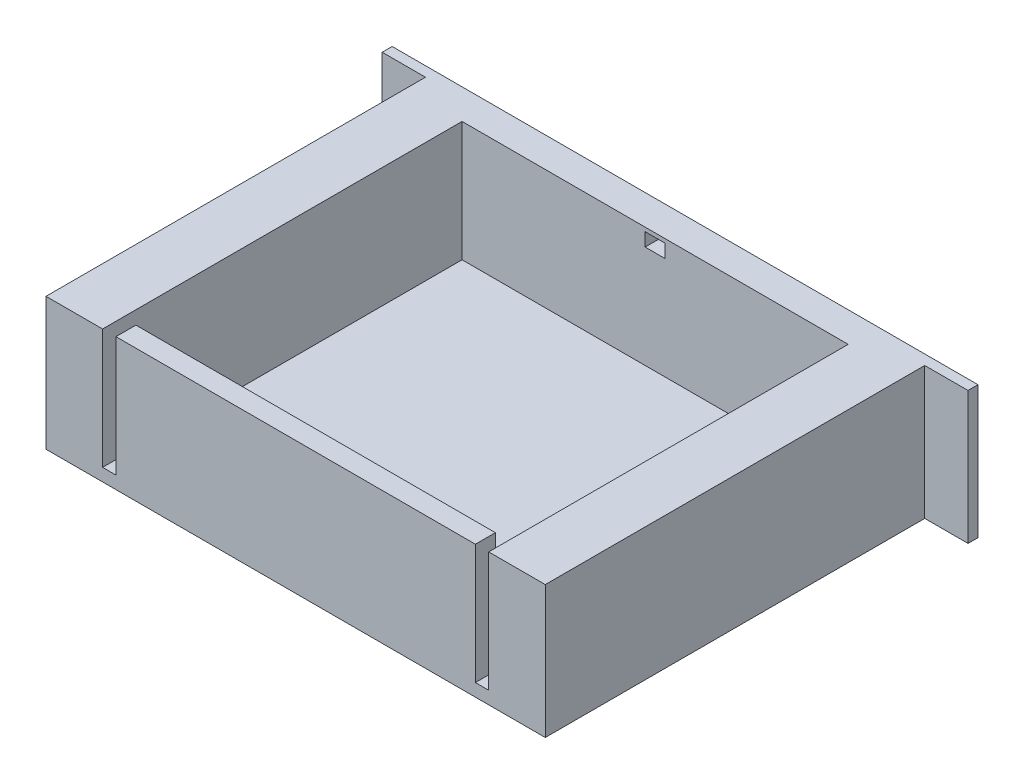
from build123d import *

# Parameters (mm, degrees)
SZKIC1_W                    = 75
SZKIC1_H                    = 19.9
DODANIE_WYCI_GNI_CIE1_DEPTH = 57
SZKIC2_W                    = 88
SZKIC2_H                    = 19.9
DODANIE_WYCI_GNI_CIE2_DEPTH = 1.5
SZKIC3_W                    = 58
SZKIC3_H                    = 51
WYTNIJ_WYCI_GNI_CIE1_DEPTH  = 18
SZKIC4_W                    = 2
SZKIC4_H                    = 3
WYTNIJ_WYCI_GNI_CIE2_DEPTH  = 18
DODANIE_WYCI_GNI_CIE3_DEPTH = 3
SZKIC6_W                    = 3
SZKIC6_H                    = 2
WYTNIJ_WYCI_GNI_CIE3_DEPTH  = 4.5


with BuildPart() as part:
    # Szkic1 → Dodanie-wyciągnięcie1 (new body)
    with BuildSketch(Plane.XY):
        with Locations((-37.5, 9.95)):
            Rectangle(SZKIC1_W, SZKIC1_H)
    extrude(amount=DODANIE_WYCI_GNI_CIE1_DEPTH)

    # Szkic2 → Dodanie-wyciągnięcie2 (add)
    with BuildSketch(Plane(origin=(0, 0, 0), x_dir=(-1, 0, 0), z_dir=(0, 0, -1))):
        with Locations((37.5, 9.95)):
            Rectangle(SZKIC2_W, SZKIC2_H)
    extrude(amount=DODANIE_WYCI_GNI_CIE2_DEPTH)

    # Szkic3 → Wytnij-wyciągnięcie1 (cut)
    with BuildSketch(Plane(origin=(0, 19.9, 0), x_dir=(1, 0, 0), z_dir=(0, 1, 0))):
        with Locations((-37.5, -28.5)):
            Rectangle(SZKIC3_W, SZKIC3_H)
    extrude(amount=-WYTNIJ_WYCI_GNI_CIE1_DEPTH, mode=Mode.SUBTRACT)

    # Szkic4 → Wytnij-wyciągnięcie2 (cut)
    with BuildSketch(Plane(origin=(0, 19.9, 0), x_dir=(1, 0, 0), z_dir=(0, 1, 0))):
        with Locations((-9.5, -55.5)):
            Rectangle(SZKIC4_W, SZKIC4_H)
        with Locations((-65.5, -55.5)):
            Rectangle(SZKIC4_W, SZKIC4_H)
    extrude(amount=-WYTNIJ_WYCI_GNI_CIE2_DEPTH, mode=Mode.SUBTRACT)

    # Szkic6 → Wytnij-wyciągnięcie3 (cut)
    with BuildSketch(Plane(origin=(0, 0, -1.5), x_dir=(-1, 0, 0), z_dir=(0, 0, -1))):
        with Locations((37.5, 18.305839867)):
            Rectangle(SZKIC6_W, SZKIC6_H)
    extrude(amount=-WYTNIJ_WYCI_GNI_CIE3_DEPTH, mode=Mode.SUBTRACT)


with BuildPart() as body_2:
    # Szkic5 → Dodanie-wyciągnięcie3 (new body)
    with BuildSketch(Plane.XZ):
        with BuildLine():
            Line((-30.003197312, -1.5), (-32.503197312, -1.5))
            ThreePointArc((-32.503197312, -1.5), (-37.503197312, -6.5), (-42.503197312, -1.5))
            Line((-42.503197312, -1.5), (-45.003197312, -1.5))
            ThreePointArc((-45.003197312, -1.5), (-37.503197312, -9), (-30.003197312, -1.5))
        make_face()
    extrude(amount=-DODANIE_WYCI_GNI_CIE3_DEPTH)


solid = Compound([part.part, body_2.part])
